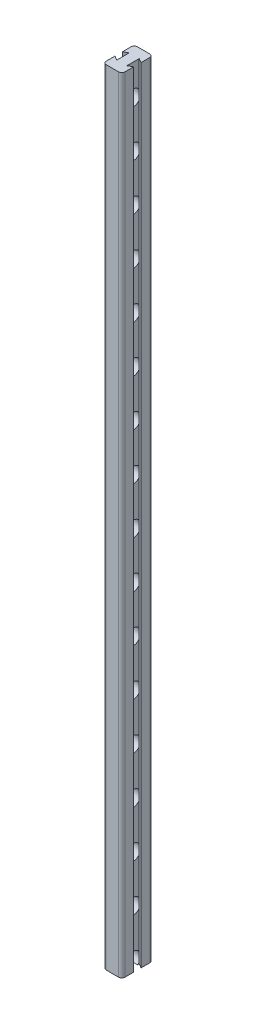
from build123d import *

# Parameters (mm, degrees)
BOSS_EXTRUDE1_DEPTH     = 1260
SKETCH3_R               = 12.5
CUT_EXTRUDE1_DEPTH      = 8
CUT_EXTRUDE1_DEPTH_BACK = 8
FILLET1_R               = 5


with BuildPart() as part:
    # Sketch1 → Boss-Extrude1 (new body)
    with BuildSketch(Plane(origin=(0, 0, 0), x_dir=(1, 0, 0), z_dir=(0, 1, 0))):
        Polygon((15, 25), (15, 5.958548116), (8, 10), (8, -10), (15, -5.958548116), (15, -25), (-15, -25), (-15, -5.958548116), (-8, -10), (-8, 10), (-15, 5.958548116), (-15, 25), align=None)
    extrude(amount=BOSS_EXTRUDE1_DEPTH)

    # Sketch3 → Cut-Extrude1 (cut, two sides)
    with BuildSketch(Plane(origin=(0, 0, 0), x_dir=(0, 0, -1), z_dir=(1, 0, 0))) as cut_extrude1_sk:
        with Locations((0, 1210)):
            Circle(SKETCH3_R)
        with Locations((0, 1135)):
            Circle(SKETCH3_R)
        with Locations((0, 1060)):
            Circle(SKETCH3_R)
        with Locations((0, 985)):
            Circle(SKETCH3_R)
        with Locations((0, 910)):
            Circle(SKETCH3_R)
        with Locations((0, 835)):
            Circle(SKETCH3_R)
        with Locations((0, 760)):
            Circle(SKETCH3_R)
        with Locations((0, 685)):
            Circle(SKETCH3_R)
        with Locations((0, 610)):
            Circle(SKETCH3_R)
        with Locations((0, 535)):
            Circle(SKETCH3_R)
        with Locations((0, 460)):
            Circle(SKETCH3_R)
        with Locations((0, 385)):
            Circle(SKETCH3_R)
        with Locations((0, 310)):
            Circle(SKETCH3_R)
        with Locations((0, 235)):
            Circle(SKETCH3_R)
        with Locations((0, 160)):
            Circle(SKETCH3_R)
        with Locations((0, 85)):
            Circle(SKETCH3_R)
        with Locations((0, 10)):
            Circle(SKETCH3_R)
    extrude(amount=CUT_EXTRUDE1_DEPTH, mode=Mode.SUBTRACT)
    extrude(cut_extrude1_sk.sketch, amount=-CUT_EXTRUDE1_DEPTH_BACK, mode=Mode.SUBTRACT)

    # Fillet1
    fillet1_edges = [part.edges().sort_by_distance(p)[0] for p in [
        (15, 630, -25),
        (15, 630, 25),
        (-15, 630, 25),
        (-15, 630, -25),
    ]]
    fillet(fillet1_edges, radius=FILLET1_R)


solid = part.part
